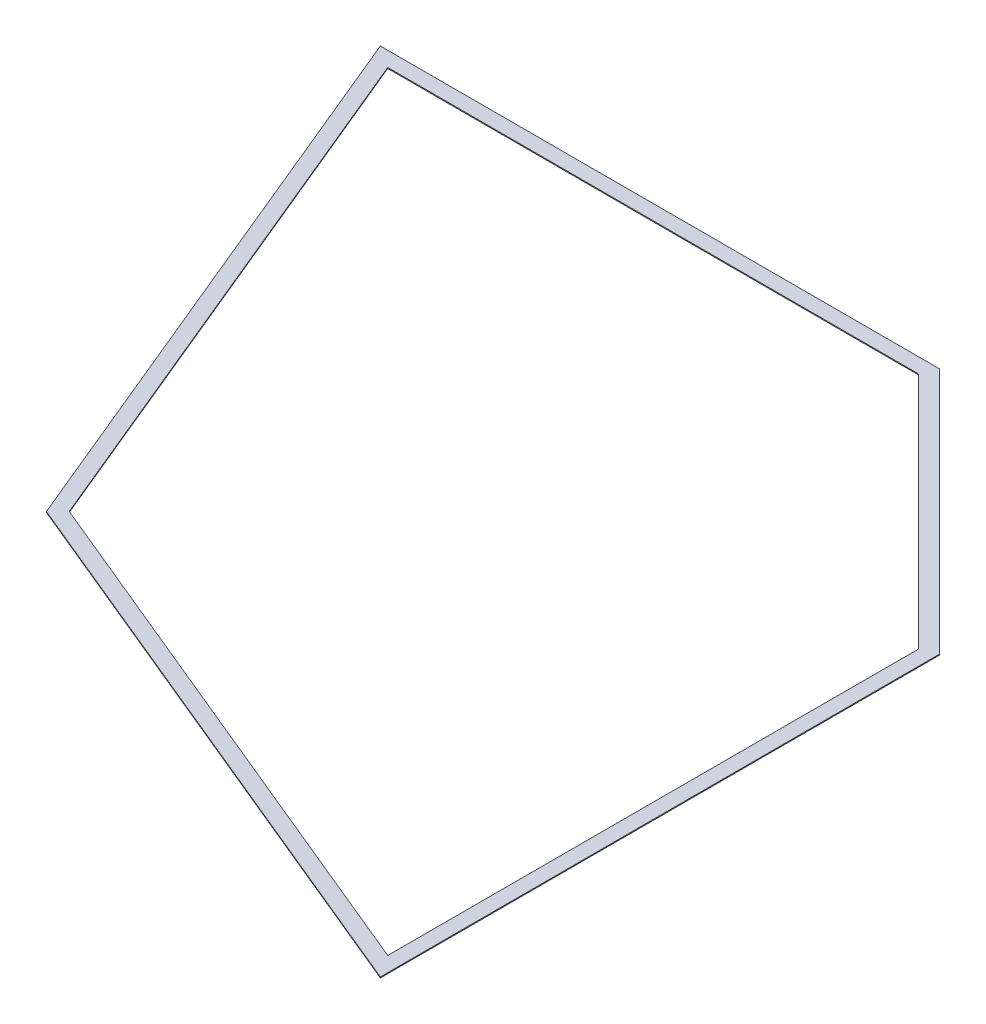
from build123d import *

# Parameters (mm, degrees)
BOSS_EXTRUDE1_DEPTH = 3.175


with BuildPart() as part:
    # Sketch1 → Boss-Extrude1 (new body)
    with BuildSketch(Plane(origin=(0, 0, 0), x_dir=(1, 0, 0), z_dir=(0, 1, 0))):
        Polygon((-1029.499704405, -187.325), (-187.325, -1029.499704405), (-187.325, -2936.301466338), (-2131.14490067, -2131.14490067), (-2936.301466338, -187.325), align=None)
        Polygon((-238.125, -1050.541753373), (-238.125, -2860.273893594), (-2092.264263941, -2092.264263941), (-2860.273893594, -238.125), (-1050.541753373, -238.125), align=None, mode=Mode.SUBTRACT)
    extrude(amount=BOSS_EXTRUDE1_DEPTH)


solid = part.part
